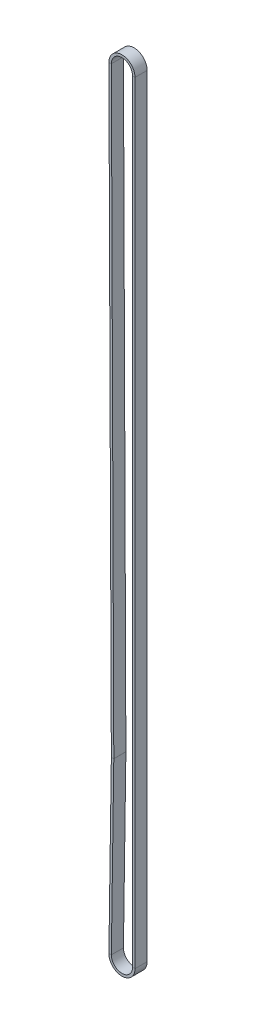
from build123d import *

# Parameters (mm, degrees)
SKETCH3_W = 1.5
SKETCH3_H = 7.366


with BuildPart() as part:
    # Sweep2: sweep along a path in Sketch2
    with BuildLine(Plane.XY) as sweep2_path:
        Line((7.218056998, -470.662), (7.218056998, 0))
        ThreePointArc((7.218056998, 0), (-0.014693633, 7.218042042), (-7.217997175, -0.029387206))
        Line((-7.217997175, -0.029387206), (-5.727022005, -366.238231444))
        ThreePointArc((-5.727022005, -366.238231444), (-5.727034648, -366.262604814), (-5.727271041, -366.286977041))
        Line((-5.727271041, -366.286977041), (-7.217320128, -470.558864231))
        ThreePointArc((-7.217320128, -470.558864231), (-0.051569201, -477.879872778), (7.218056998, -470.662))
    # Sketch3 → Sweep2 (sweep)
    with BuildSketch(Plane(origin=(0, 0, 0), x_dir=(1, 0, 0), z_dir=(0, 1, 0))):
        with Locations((-7.218057041, -3.683)):
            Rectangle(SKETCH3_W, SKETCH3_H)
    sweep(path=sweep2_path.line)


solid = part.part
